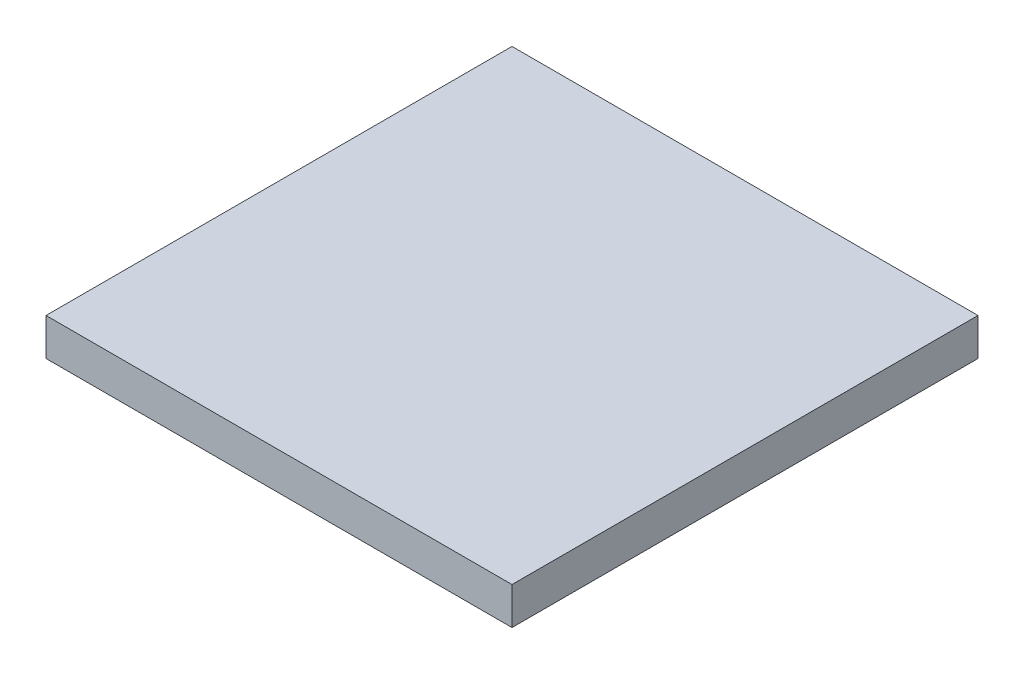
from build123d import *

# Parameters (mm, degrees)
SKETCH_1_W      = 25
SKETCH_1_H      = 25
EXTRUDE_1_DEPTH = 2


with BuildPart() as part:
    # 草图1 → 凸台-拉伸1 (new body)
    with BuildSketch(Plane(origin=(0, 0, 0), x_dir=(1, 0, 0), z_dir=(0, 1, 0))):
        Rectangle(SKETCH_1_W, SKETCH_1_H)
    extrude(amount=EXTRUDE_1_DEPTH)


solid = part.part
